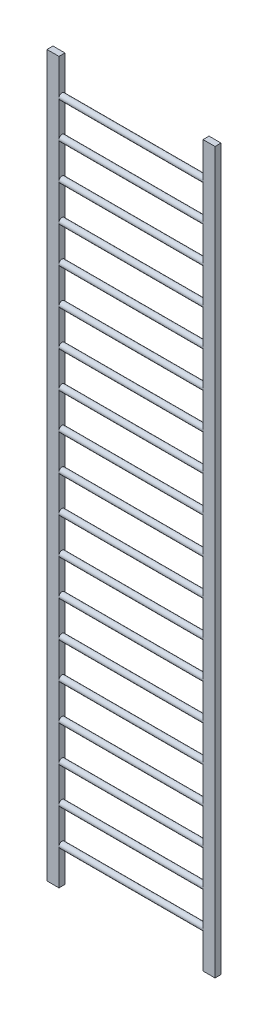
from build123d import *

# Parameters (mm, degrees)
ESBO_O1_W                     = 100
ESBO_O1_H                     = 50
RESSALTO_EXTRUS_O1_DEPTH      = 6000
RESSALTO_EXTRUS_O1_2_DEPTH    = 6000
ESBO_O4_R                     = 25
RESSALTO_EXTRUS_O3_DEPTH      = 600
RESSALTO_EXTRUS_O3_DEPTH_BACK = 700


with BuildPart() as part:
    # Esboço1 → Ressalto-extrusão1 (new body)
    with BuildSketch(Plane(origin=(0, 0, 0), x_dir=(1, 0, 0), z_dir=(0, 1, 0))):
        with Locations((650, 0)):
            Rectangle(ESBO_O1_W, ESBO_O1_H)
    extrude(amount=RESSALTO_EXTRUS_O1_DEPTH)



with BuildPart() as body_2:
    # Esboço1 → Ressalto-extrus_o1 2 (new body)
    with BuildSketch(Plane(origin=(0, 0, 0), x_dir=(1, 0, 0), z_dir=(0, 1, 0))):
        with Locations((-650, 0)):
            Rectangle(ESBO_O1_W, ESBO_O1_H)
    extrude(amount=RESSALTO_EXTRUS_O1_2_DEPTH)


with BuildPart() as part_1:
    add(part.part)

    add(body_2.part)  # Ressalto-extrusão3 merges body 2
    # Esboço4 → Ressalto-extrusão3 (add, two sides)
    with BuildSketch(Plane(origin=(0, 0, 0), x_dir=(0, 0, -1), z_dir=(1, 0, 0))) as ressalto_extrus_o3_sk:
        with Locations((0, 300)):
            Circle(ESBO_O4_R)
        with Locations((0, 600)):
            Circle(ESBO_O4_R)
        with Locations((0, 900)):
            Circle(ESBO_O4_R)
        with Locations((0, 1200)):
            Circle(ESBO_O4_R)
        with Locations((0, 1500)):
            Circle(ESBO_O4_R)
        with Locations((0, 1800)):
            Circle(ESBO_O4_R)
        with Locations((0, 2100)):
            Circle(ESBO_O4_R)
        with Locations((0, 2400)):
            Circle(ESBO_O4_R)
        with Locations((0, 2700)):
            Circle(ESBO_O4_R)
        with Locations((0, 3000)):
            Circle(ESBO_O4_R)
        with Locations((0, 3300)):
            Circle(ESBO_O4_R)
        with Locations((0, 3600)):
            Circle(ESBO_O4_R)
        with Locations((0, 3900)):
            Circle(ESBO_O4_R)
        with Locations((0, 4200)):
            Circle(ESBO_O4_R)
        with Locations((0, 4500)):
            Circle(ESBO_O4_R)
        with Locations((0, 4800)):
            Circle(ESBO_O4_R)
        with Locations((0, 5100)):
            Circle(ESBO_O4_R)
        with Locations((0, 5400)):
            Circle(ESBO_O4_R)
        with Locations((0, 5700)):
            Circle(ESBO_O4_R)
    extrude(amount=RESSALTO_EXTRUS_O3_DEPTH)
    extrude(ressalto_extrus_o3_sk.sketch, amount=-RESSALTO_EXTRUS_O3_DEPTH_BACK)


solid = part_1.part
